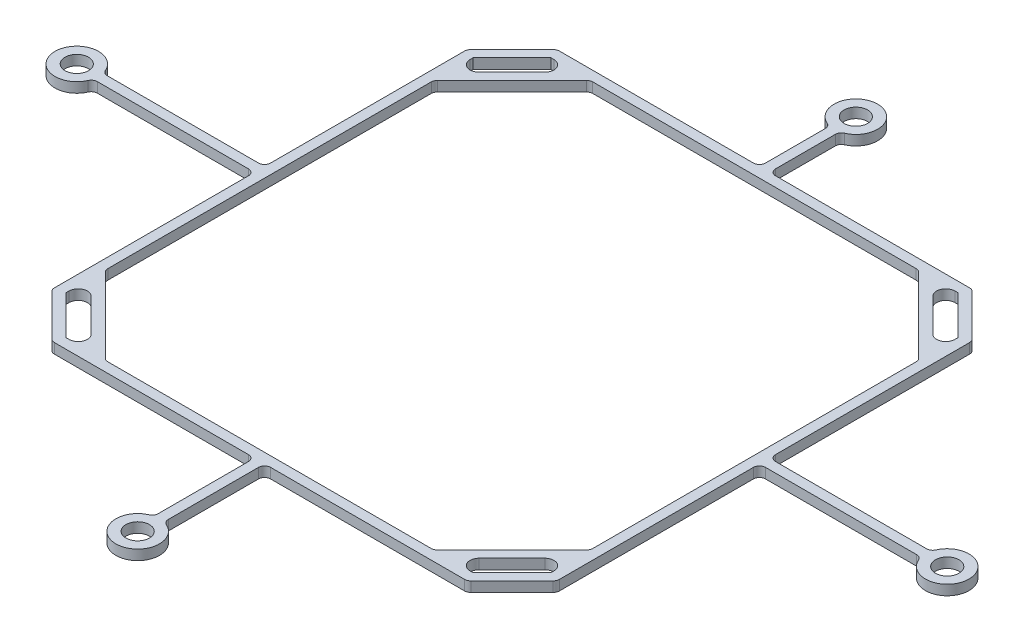
from build123d import *

# Parameters (mm, degrees)
SKETCH1_R           = 1.925
BOSS_EXTRUDE1_DEPTH = 1.65
FILLET4_R           = 1
FILLET3_R           = 1.5
FILLET5_R           = 1


with BuildPart() as part:
    # Sketch1 → Boss-Extrude1 (new body)
    with BuildSketch(Plane(origin=(0, 0, 0), x_dir=(1, 0, 0), z_dir=(0, 1, 0))):
        with BuildLine():
            Line((-41.448800006, 34.091704203), (-34.091704203, 41.448800006))
            Line((-34.091704203, 41.448800006), (-0.825, 41.448800006))
            Line((-0.825, 41.448800006), (-0.825, 52.97029458))
            ThreePointArc((-0.825, 52.97029458), (0, 60.023800006), (0.825, 52.97029458))
            Line((0.825, 52.97029458), (0.825, 41.448800006))
            Line((0.825, 41.448800006), (34.091704203, 41.448800006))
            Line((34.091704203, 41.448800006), (41.448800006, 34.091704203))
            Line((41.448800006, 34.091704203), (41.448800006, 0.825))
            Line((41.448800006, 0.825), (67.97029458, 0.825))
            ThreePointArc((67.97029458, 0.825), (75.023800006, 0), (67.97029458, -0.825))
            Line((67.97029458, -0.825), (41.448800006, -0.825))
            Line((41.448800006, -0.825), (41.448800006, -34.091704203))
            Line((41.448800006, -34.091704203), (34.091704203, -41.448800006))
            Line((34.091704203, -41.448800006), (0.825, -41.448800006))
            Line((0.825, -41.448800006), (0.825, -57.97029458))
            ThreePointArc((0.825, -57.97029458), (0, -65.023800006), (-0.825, -57.97029458))
            Line((-0.825, -57.97029458), (-0.825, -41.448800006))
            Line((-0.825, -41.448800006), (-34.091704203, -41.448800006))
            Line((-34.091704203, -41.448800006), (-41.448800006, -34.091704203))
            Line((-41.448800006, -34.091704203), (-41.448800006, -0.825))
            Line((-41.448800006, -0.825), (-67.97029458, -0.825))
            ThreePointArc((-67.97029458, -0.825), (-75.023800006, 0), (-67.97029458, 0.825))
            Line((-67.97029458, 0.825), (-41.448800006, 0.825))
            Line((-41.448800006, 0.825), (-41.448800006, 34.091704203))
        make_face()
        with Locations((0, 56.448800006)):
            Circle(SKETCH1_R, mode=Mode.SUBTRACT)
        with Locations((71.448800006, 0)):
            Circle(SKETCH1_R, mode=Mode.SUBTRACT)
        with Locations((0, -61.448800006)):
            Circle(SKETCH1_R, mode=Mode.SUBTRACT)
        with Locations((-71.448800006, 0)):
            Circle(SKETCH1_R, mode=Mode.SUBTRACT)
        Polygon((-39.798800006, 33.408251825), (-33.408251825, 39.798800006), (-29.292890359, 39.798800006), (-39.798800006, 29.292890359), align=None, mode=Mode.SUBTRACT)
        Polygon((-33.408251825, -39.798800006), (-29.292890359, -39.798800006), (-39.798800006, -29.292890359), (-39.798800006, -33.408251825), align=None, mode=Mode.SUBTRACT)
        Polygon((39.798800006, -33.408251825), (39.798800006, -29.292890359), (29.292890359, -39.798800006), (33.408251825, -39.798800006), align=None, mode=Mode.SUBTRACT)
        Polygon((33.408251825, 39.798800006), (39.798800006, 33.408251825), (39.798800006, 29.292890359), (29.292890359, 39.798800006), align=None, mode=Mode.SUBTRACT)
        Polygon((-39.798800006, 26.959437981), (-26.959437981, 39.798800006), (26.959437981, 39.798800006), (39.798800006, 26.959437981), (39.798800006, -26.959437981), (26.959437981, -39.798800006), (-26.959437981, -39.798800006), (-39.798800006, -26.959437981), align=None, mode=Mode.SUBTRACT)
    extrude(amount=BOSS_EXTRUDE1_DEPTH)

    # Fillet4
    fillet4_edges = [part.edges().sort_by_distance(p)[0] for p in [
        (-0.825, 0.825, -41.448800006),
        (-0.825, 0.825, -52.97029458),
        (0.825, 0.825, -52.97029458),
        (0.825, 0.825, -41.448800006),
        (41.448800006, 0.825, -0.825),
        (67.97029458, 0.825, -0.825),
        (67.97029458, 0.825, 0.825),
        (41.448800006, 0.825, 0.825),
        (0.825, 0.825, 41.448800006),
        (0.825, 0.825, 57.97029458),
        (-0.825, 0.825, 57.97029458),
        (-0.825, 0.825, 41.448800006),
        (-41.448800006, 0.825, 0.825),
        (-67.97029458, 0.825, 0.825),
        (-67.97029458, 0.825, -0.825),
        (-41.448800006, 0.825, -0.825),
    ]]
    fillet(fillet4_edges, radius=FILLET4_R)

    # Fillet3
    fillet3_edges = [part.edges().sort_by_distance(p)[0] for p in [
        (-29.292890359, 0.825, 39.798800006),
        (-39.798800006, 0.825, 29.292890359),
        (-39.798800006, 0.825, -29.292890359),
        (-29.292890359, 0.825, -39.798800006),
        (29.292890359, 0.825, -39.798800006),
        (39.798800006, 0.825, -29.292890359),
        (39.798800006, 0.825, 29.292890359),
        (29.292890359, 0.825, 39.798800006),
    ]]
    fillet(fillet3_edges, radius=FILLET3_R)

    # Fillet5
    fillet5_edges = [part.edges().sort_by_distance(p)[0] for p in [
        (-39.798800006, 0.825, -26.959437981),
        (-39.798800006, 0.825, 26.959437981),
        (-26.959437981, 0.825, 39.798800006),
        (26.959437981, 0.825, 39.798800006),
        (39.798800006, 0.825, 26.959437981),
        (39.798800006, 0.825, -26.959437981),
        (26.959437981, 0.825, -39.798800006),
        (-26.959437981, 0.825, -39.798800006),
        (-41.448800006, 0.825, -34.091704203),
        (-34.091704203, 0.825, -41.448800006),
        (34.091704203, 0.825, -41.448800006),
        (41.448800006, 0.825, -34.091704203),
        (41.448800006, 0.825, 34.091704203),
        (34.091704203, 0.825, 41.448800006),
        (-34.091704203, 0.825, 41.448800006),
        (-41.448800006, 0.825, 34.091704203),
    ]]
    fillet(fillet5_edges, radius=FILLET5_R)


solid = part.part
